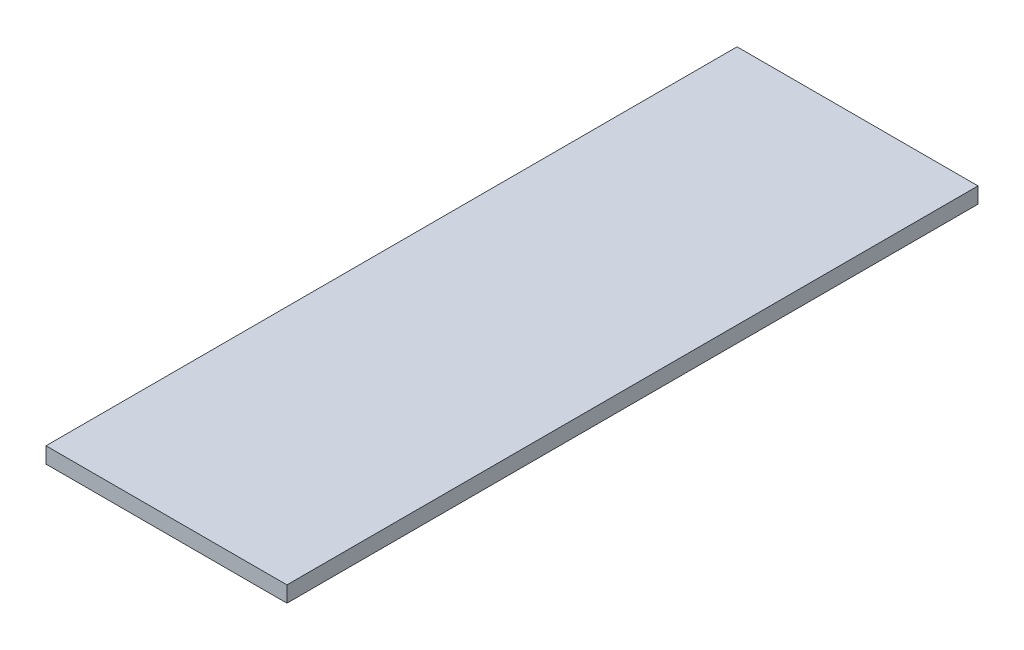
from build123d import *

# Parameters (mm, degrees)
SKETCH1_W           = 48.175
SKETCH1_H           = 138.175
BOSS_EXTRUDE1_DEPTH = 3.175


with BuildPart() as part:
    # Sketch1 → Boss-Extrude1 (new body)
    with BuildSketch(Plane(origin=(0, 0, 0), x_dir=(1, 0, 0), z_dir=(0, 1, 0))):
        Rectangle(SKETCH1_W, SKETCH1_H)
    extrude(amount=BOSS_EXTRUDE1_DEPTH)


solid = part.part
